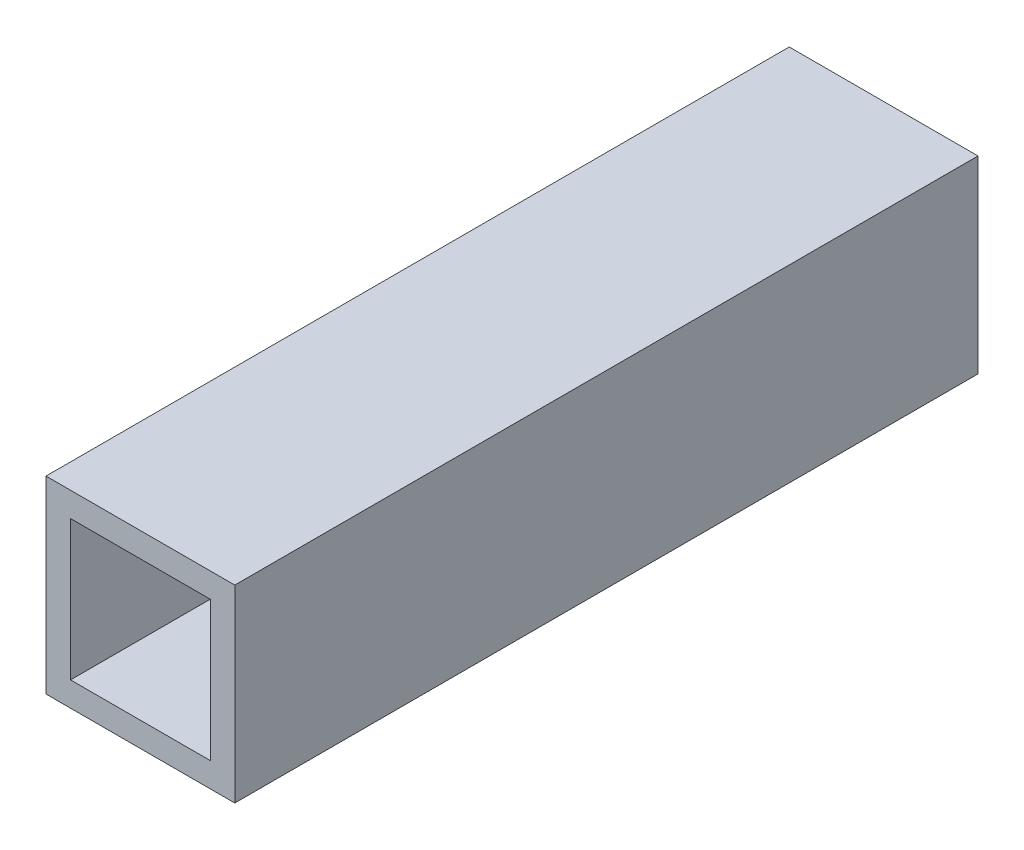
from build123d import *

# Parameters (mm, degrees)
SKETCH1_W           = 12.7
SKETCH1_H           = 12.7
SKETCH1_W_2         = 9.4
SKETCH1_H_2         = 9.4
BOSS_EXTRUDE1_DEPTH = 50


with BuildPart() as part:
    # Sketch1 → Boss-Extrude1 (new body)
    with BuildSketch(Plane.XY):
        Rectangle(SKETCH1_W, SKETCH1_H)
        Rectangle(SKETCH1_W_2, SKETCH1_H_2, mode=Mode.SUBTRACT)
    extrude(amount=BOSS_EXTRUDE1_DEPTH)


solid = part.part
